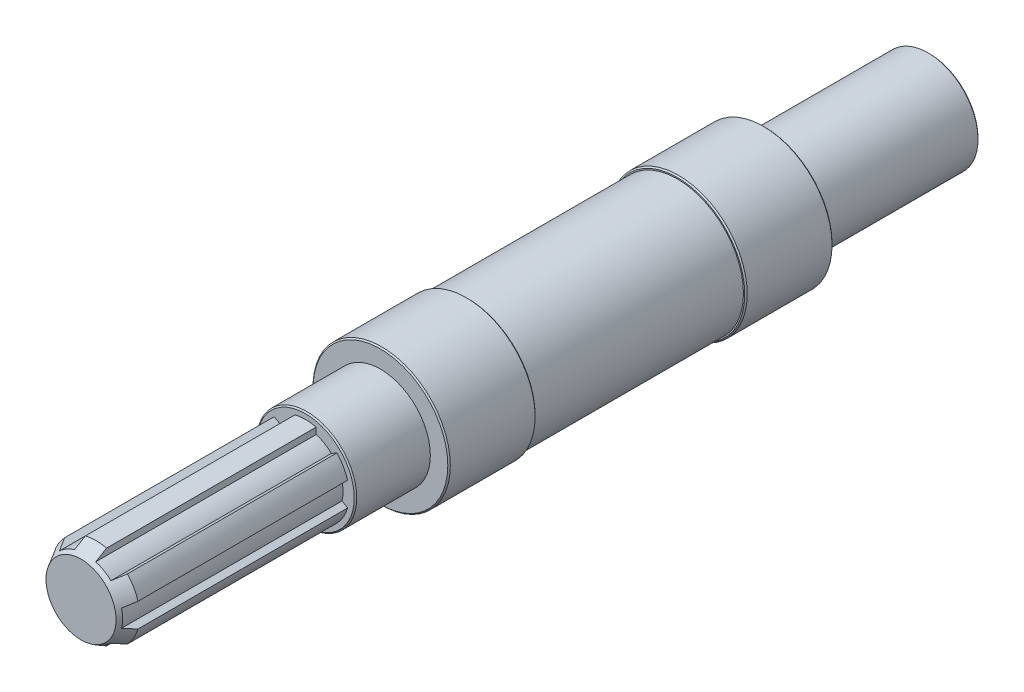
from build123d import *
from build123d.topology import SkipClean

# Parameters (mm, degrees)
SKICA1_R                  = 20
P_IDAT_VYSUNUT_M1_DEPTH   = 66
SKICA2_R                  = 27.5
P_IDAT_VYSUNUT_M2_DEPTH   = 35
SKICA3_R                  = 26.5
P_IDAT_VYSUNUT_M3_DEPTH   = 84
SKICA4_R                  = 27.5
P_IDAT_VYSUNUT_M4_DEPTH   = 35
SKICA5_R                  = 20
P_IDAT_VYSUNUT_M5_DEPTH   = 30
SKICA6_R                  = 17.5
P_IDAT_VYSUNUT_M6_DEPTH   = 90
ZKOSEN_3_SIZE             = 6
ZKOSEN_3_SIZE2            = 3.464101615
SKICA9_OUTSIDE_W          = 126.756
SKICA9_OUTSIDE_H          = 126.756
ODEBRAT_VYSUNUT_M16_DEPTH = 90
ZKOSEN_4_SIZE             = 0.5
M10_Z_VIT1_D              = 8.5
M10_Z_VIT1_DEPTH          = 30
M10_Z_VIT1_TIP            = 2.553657631
ODEBRAT_START             = -15
ODEBRAT_VYSUNUT_M17_DEPTH = 13.5


with BuildPart() as part:
    # Skica1 → P_idat vysunut_m1 (new body)
    with BuildSketch(Plane.XY):
        Circle(SKICA1_R)
    extrude(amount=P_IDAT_VYSUNUT_M1_DEPTH)

    # Skica2 → P_idat vysunut_m2 (add)
    with BuildSketch(Plane.XY.offset(66)):
        Circle(SKICA2_R)
    extrude(amount=P_IDAT_VYSUNUT_M2_DEPTH)

    # Skica3 → P_idat vysunut_m3 (add)
    with BuildSketch(Plane.XY.offset(101)):
        Circle(SKICA3_R)
    extrude(amount=P_IDAT_VYSUNUT_M3_DEPTH)

    # Skica4 → P_idat vysunut_m4 (add)
    with BuildSketch(Plane.XY.offset(185)):
        Circle(SKICA4_R)
    extrude(amount=P_IDAT_VYSUNUT_M4_DEPTH)

    # Skica5 → P_idat vysunut_m5 (add)
    with BuildSketch(Plane.XY.offset(220)):
        Circle(SKICA5_R)
    extrude(amount=P_IDAT_VYSUNUT_M5_DEPTH)

    # Skica6 → P_idat vysunut_m6 (add)
    with BuildSketch(Plane.XY.offset(250)):
        Circle(SKICA6_R)
    extrude(amount=P_IDAT_VYSUNUT_M6_DEPTH)

    # Zkosen_3
    zkosen_3_edges = [part.edges().sort_by_distance(p)[0] for p in [
        (-17.5, 0, 340),
    ]]
    zkosen_3_side = [part.faces().sort_by_distance(p)[0] for p in [
        (-17.5, 0, 295),
    ]]
    chamfer(zkosen_3_edges, length=ZKOSEN_3_SIZE, length2=ZKOSEN_3_SIZE2, reference=zkosen_3_side[0])

    # Skica9 outside → Odebrat vysunut_m16 (cut)
    with BuildSketch(Plane.XY.offset(340)):
        Rectangle(SKICA9_OUTSIDE_W, SKICA9_OUTSIDE_H)
        with BuildLine():
            Line((-4.25, 14.385322381), (-4.25, 16.976086121))
            ThreePointArc((-4.25, 16.976086121), (0, 17.5), (4.25, 16.976086121))
            Line((4.25, 16.976086121), (4.25, 14.385322381))
            ThreePointArc((4.25, 14.385322381), (7.5, 12.990381057), (10.333054623, 10.873269156))
            Line((10.333054623, 10.873269156), (12.576721838, 12.168651027))
            ThreePointArc((12.576721838, 12.168651027), (15.155444566, 8.75), (16.826721838, 4.807435095))
            Line((16.826721838, 4.807435095), (14.583054623, 3.512053224))
            ThreePointArc((14.583054623, 3.512053224), (15, 0), (14.583054623, -3.512053224))
            Line((14.583054623, -3.512053224), (16.826721838, -4.807435095))
            ThreePointArc((16.826721838, -4.807435095), (15.155444566, -8.75), (12.576721838, -12.168651027))
            Line((12.576721838, -12.168651027), (10.333054623, -10.873269156))
            ThreePointArc((10.333054623, -10.873269156), (7.5, -12.990381057), (4.25, -14.385322381))
            Line((4.25, -14.385322381), (4.25, -16.976086121))
            ThreePointArc((4.25, -16.976086121), (0, -17.5), (-4.25, -16.976086121))
            Line((-4.25, -16.976086121), (-4.25, -14.385322381))
            ThreePointArc((-4.25, -14.385322381), (-7.5, -12.990381057), (-10.333054623, -10.873269156))
            Line((-10.333054623, -10.873269156), (-12.576721838, -12.168651027))
            ThreePointArc((-12.576721838, -12.168651027), (-15.155444566, -8.75), (-16.826721838, -4.807435095))
            Line((-16.826721838, -4.807435095), (-14.583054623, -3.512053224))
            ThreePointArc((-14.583054623, -3.512053224), (-15, 0), (-14.583054623, 3.512053224))
            Line((-14.583054623, 3.512053224), (-16.826721838, 4.807435095))
            ThreePointArc((-16.826721838, 4.807435095), (-15.155444566, 8.75), (-12.576721838, 12.168651027))
            Line((-12.576721838, 12.168651027), (-10.333054623, 10.873269156))
            ThreePointArc((-10.333054623, 10.873269156), (-7.5, 12.990381057), (-4.25, 14.385322381))
        make_face(mode=Mode.SUBTRACT)
    extrude(amount=-ODEBRAT_VYSUNUT_M16_DEPTH, mode=Mode.SUBTRACT)

    # Zkosen_4
    zkosen_4_edges = [part.edges().sort_by_distance(p)[0] for p in [
        (-27.5, 0, 185),
        (-27.5, 0, 220),
        (-20, 0, 0),
        (-20, 0, 250),
        (-27.5, 0, 66),
        (-27.5, 0, 101),
    ]]
    chamfer(zkosen_4_edges, length=ZKOSEN_4_SIZE)

    # M10 z_vit1
    with Locations(Plane(origin=(0, 0, 0), x_dir=(-1, 0, 0), z_dir=(0, 0, -1))):
        with Locations((0, 0)):
            Hole(M10_Z_VIT1_D / 2, depth=M10_Z_VIT1_DEPTH)
            with Locations((0, 0, -(M10_Z_VIT1_DEPTH + M10_Z_VIT1_TIP / 2))):  # 118° drill point
                Cone(0, M10_Z_VIT1_D / 2, M10_Z_VIT1_TIP, mode=Mode.SUBTRACT)

    # Skica12 → Odebrat vysunut_m17 (cut, through all)
    with SkipClean():  # keep this step's faces unmerged: merging them makes the solid invalid here
        with BuildSketch(Plane(origin=(0, 0, 0), x_dir=(1, 0, 0), z_dir=(0, 1, 0)).offset(ODEBRAT_START)):
            with BuildLine():
                Line((-7, 0), (-7, -58.99999898))
                ThreePointArc((-7, -58.99999898), (0, -66), (7, -58.99999898))
                Line((7, -58.99999898), (7, 0))
                Line((7, 0), (-7, 0))
            make_face()
        extrude(amount=-ODEBRAT_VYSUNUT_M17_DEPTH, mode=Mode.SUBTRACT)


solid = part.part
